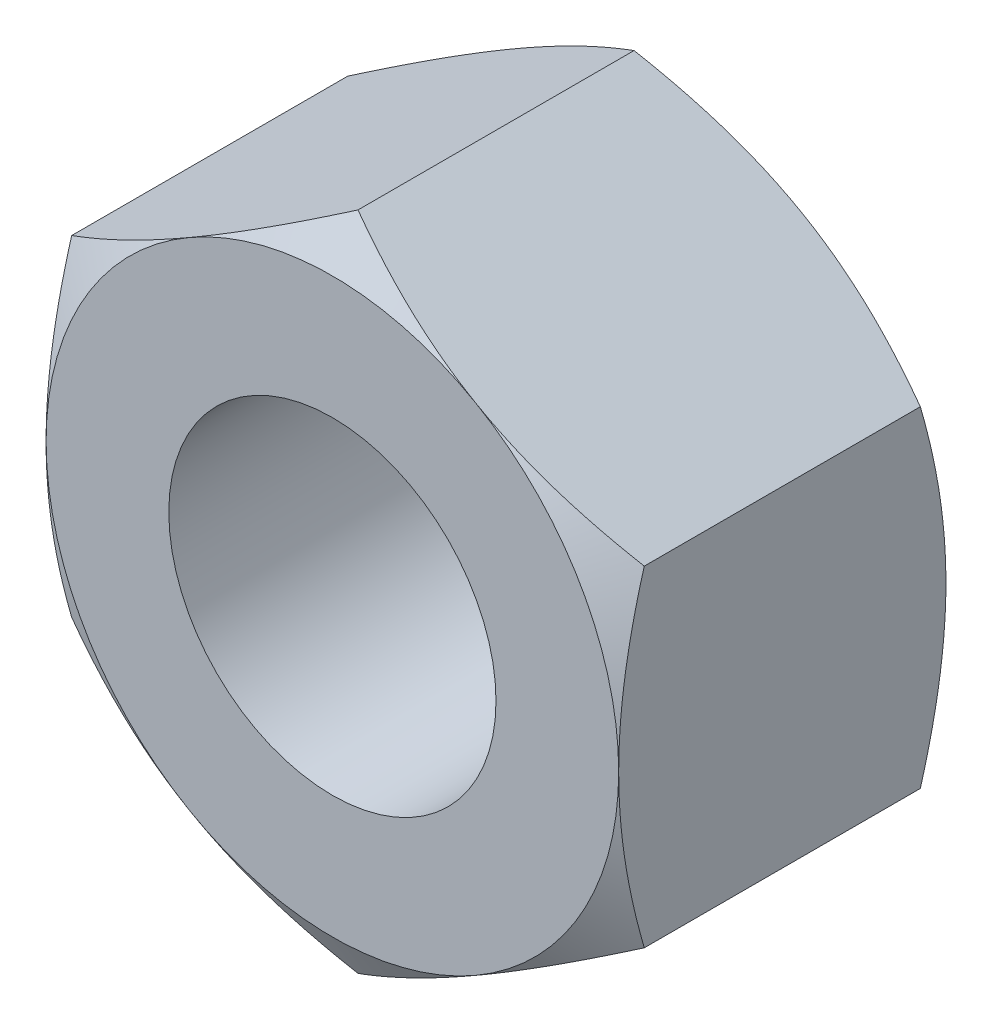
from build123d import *

# Parameters (mm, degrees)
BOSS_EXTRU_1_DEPTH      = 4
ENL_V_MAT_EXTRU_1_REACH = 6
ESQUISSE2_R             = 2


with BuildPart() as part:
    # Esquisse1 → Boss.-Extru.1 (new body)
    with BuildSketch(Plane.XY):
        Polygon((0, 4.041451884), (-3.5, 2.020725942), (-3.5, -2.020725942), (0, -4.041451884), (3.5, -2.020725942), (3.5, 2.020725942), align=None)
    extrude(amount=BOSS_EXTRU_1_DEPTH)

    # Esquisse2 → Enlèv. mat.-Extru.1 (cut, up to next)
    with BuildSketch(Plane.XY.offset(4), mode=Mode.PRIVATE) as enl_v_mat_extru_1_sk1:
        Circle(ESQUISSE2_R)
    enl_v_mat_extru_1_tool1 = extrude(enl_v_mat_extru_1_sk1.sketch, amount=-ENL_V_MAT_EXTRU_1_REACH, mode=Mode.PRIVATE) & part.part
    add(enl_v_mat_extru_1_tool1.solids().sort_by_distance((0, 0, 4))[0], mode=Mode.SUBTRACT)

    # Esquisse4 → Enlèvement de matière-Révolution8 (revolve, cut)
    with BuildSketch(Plane(origin=(0, 0, 0), x_dir=(1, 0, 0), z_dir=(0, 1, 0))):
        Polygon((-6.964101615, -2), (-1.767949192, 1), (-7.964101615, 1), (-7.964101615, -5), (-1.767949192, -5), align=None)
    revolve(axis=Axis((0, 0, 0), (0, 0, 1)), mode=Mode.SUBTRACT)


solid = part.part
